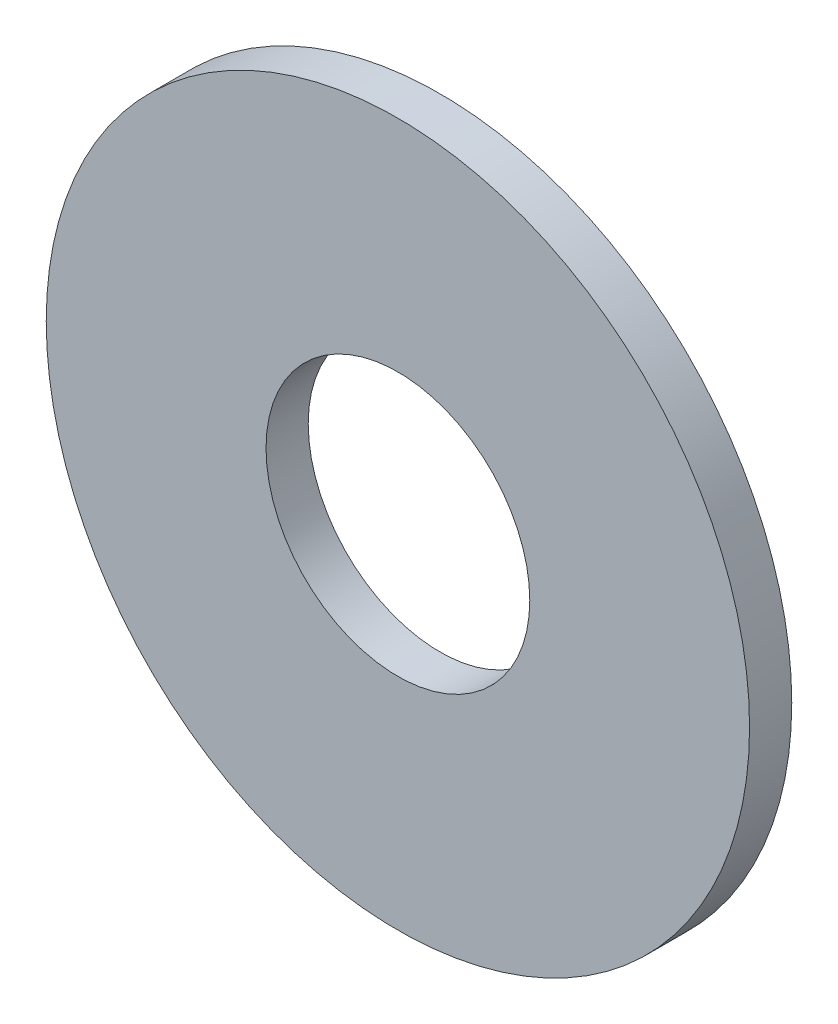
from build123d import *

# Parameters (mm, degrees)
SKETCH1_R      = 6.35
SKETCH1_R_2    = 2.38125
EXTRUDE1_DEPTH = 0.762


with BuildPart() as part:
    # Sketch1 → Extrude1 (new body)
    with BuildSketch(Plane.XY):
        Circle(SKETCH1_R)
        Circle(SKETCH1_R_2, mode=Mode.SUBTRACT)
    extrude(amount=-EXTRUDE1_DEPTH)


solid = part.part
